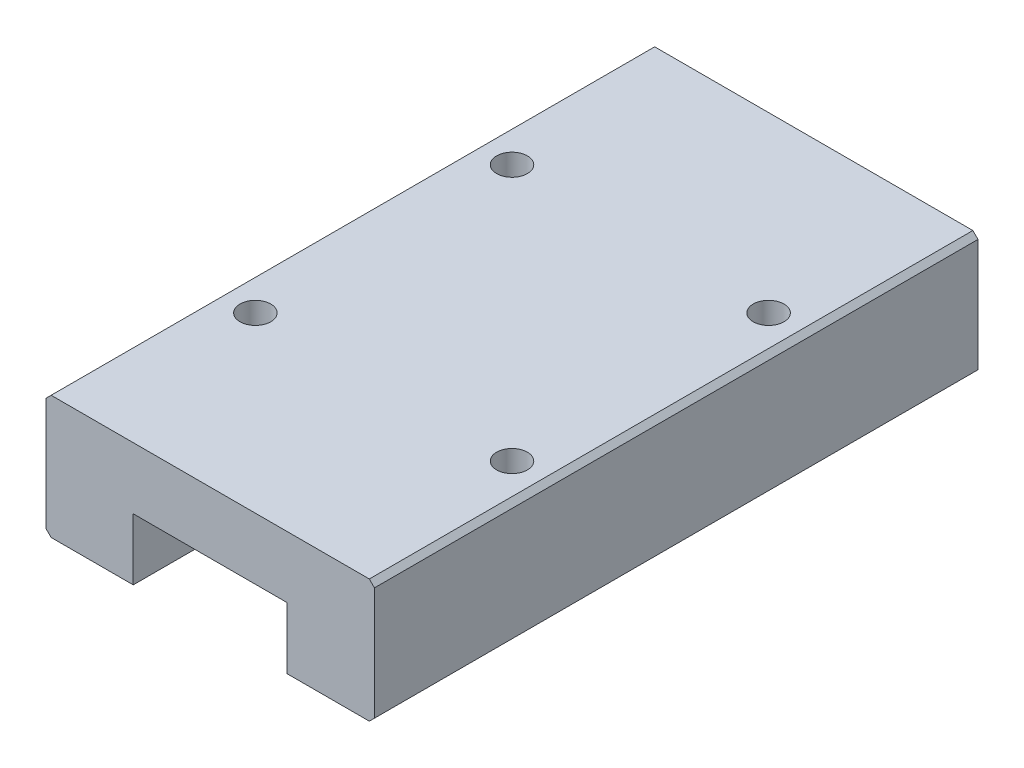
from build123d import *

# Parameters (mm, degrees)
EXTRUDE_2_DEPTH     = 58.8
SKETCH_2_R          = 1.5
CUT_EXTRUDE_1_DEPTH = 4


with BuildPart() as part:
    # 草图1 → 凸台-拉伸2 (new body)
    with BuildSketch(Plane.XY):
        Polygon((10.767605634, -1.521126761), (18.767605634, -1.521126761), (19.267605634, -1.021126761), (19.267605634, 9.978873239), (18.767605634, 10.478873239), (-12.232394366, 10.478873239), (-12.732394366, 9.978873239), (-12.732394366, -1.021126761), (-12.232394366, -1.521126761), (-4.232394366, -1.521126761), (-4.232394366, 4.478873239), (10.767605634, 4.478873239), align=None)
    extrude(amount=EXTRUDE_2_DEPTH)

    # 草图2 → 切除-拉伸1 (cut)
    with BuildSketch(Plane(origin=(0, 10.478873239, 0), x_dir=(1, 0, 0), z_dir=(0, 1, 0))):
        with Locations((-9.232394366, -41.9)):
            Circle(SKETCH_2_R)
        with Locations((-9.232394366, -16.9)):
            Circle(SKETCH_2_R)
        with Locations((15.767605634, -16.9)):
            Circle(SKETCH_2_R)
        with Locations((15.767605634, -41.9)):
            Circle(SKETCH_2_R)
    extrude(amount=-CUT_EXTRUDE_1_DEPTH, mode=Mode.SUBTRACT)


solid = part.part
